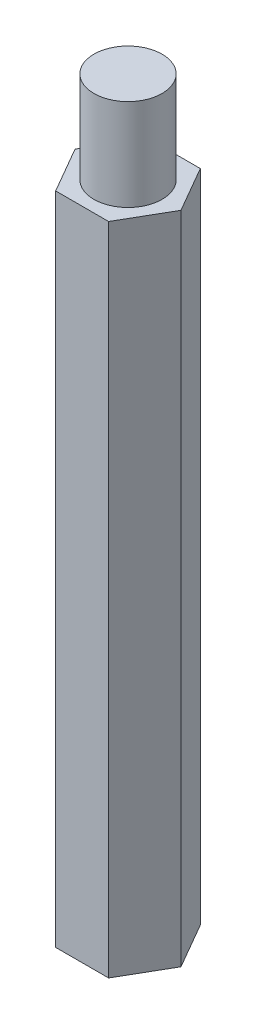
from build123d import *

# Parameters (mm, degrees)
EXTRUDE_1_DEPTH     = 50
SKETCH_2_R          = 2.6
CUT_EXTRUDE_1_DEPTH = 51
SKETCH_3_R          = 2.6
EXTRUDE_2_DEPTH     = 47


with BuildPart() as part:
    # 草图1 → 凸台-拉伸1 (new body)
    with BuildSketch(Plane(origin=(0, 0, 0), x_dir=(1, 0, 0), z_dir=(0, 1, 0))):
        Polygon((4.041451884, 0), (2.020725942, 3.5), (-2.020725942, 3.5), (-4.041451884, 0), (-2.020725942, -3.5), (2.020725942, -3.5), align=None)
    extrude(amount=EXTRUDE_1_DEPTH)

    # 草图2 → 切除-拉伸1 (cut, through all)
    with BuildSketch(Plane(origin=(0, 50, 0), x_dir=(1, 0, 0), z_dir=(0, 1, 0))):
        Circle(SKETCH_2_R)
    extrude(amount=-CUT_EXTRUDE_1_DEPTH, mode=Mode.SUBTRACT)

    # 草图3 → 凸台-拉伸2 (add)
    with BuildSketch(Plane(origin=(0, 10, 0), x_dir=(-1, 0, 0), z_dir=(0, -1, 0))):
        Circle(SKETCH_3_R)
    extrude(amount=-EXTRUDE_2_DEPTH)


solid = part.part
